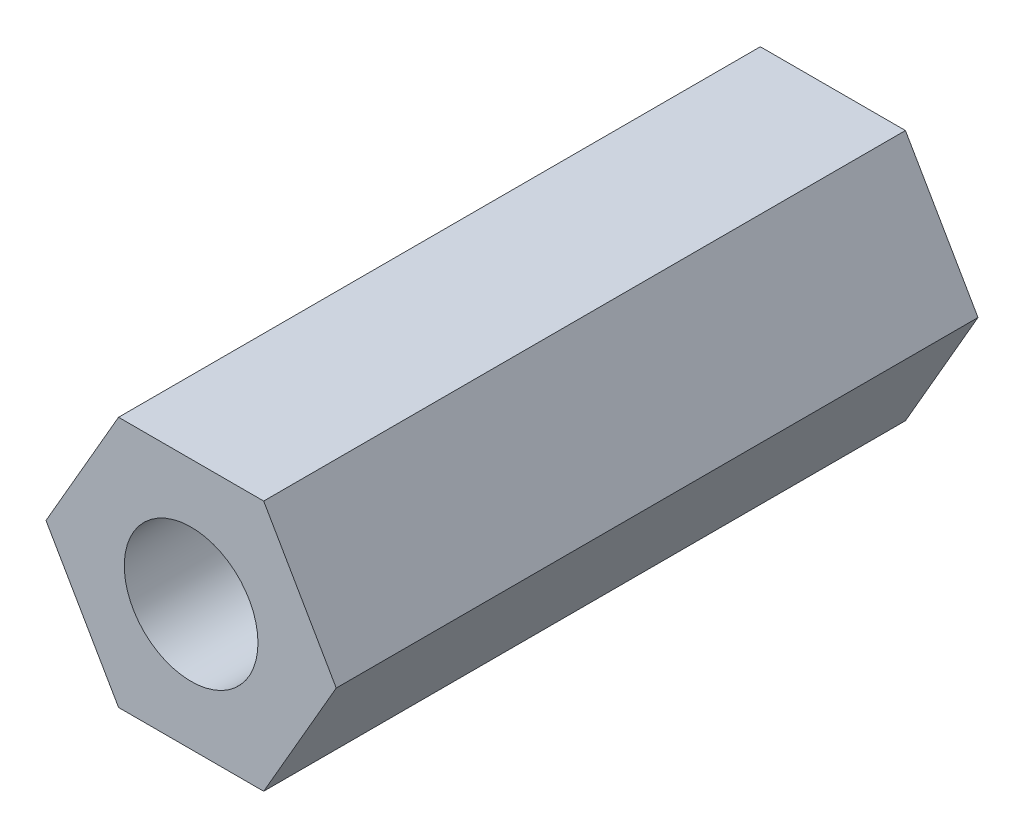
from build123d import *

# Parameters (mm, degrees)
SKETCH1_R           = 1.25
BOSS_EXTRUDE1_DEPTH = 12


with BuildPart() as part:
    # Sketch1 → Boss-Extrude1 (new body)
    with BuildSketch(Plane.XY):
        Polygon((2.713546265, 0), (1.356773133, 2.35), (-1.356773133, 2.35), (-2.713546265, 0), (-1.356773133, -2.35), (1.356773133, -2.35), align=None)
        Circle(SKETCH1_R, mode=Mode.SUBTRACT)
    extrude(amount=BOSS_EXTRUDE1_DEPTH)


solid = part.part
